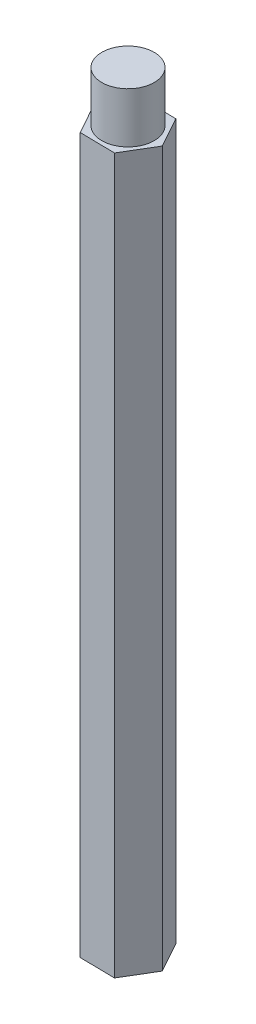
from build123d import *

# Parameters (mm, degrees)
BOSS_EXTRUDE1_DEPTH = 45
SKETCH2_R           = 1.65
BOSS_EXTRUDE2_DEPTH = 3.175


with BuildPart() as part:
    # Sketch1 → Boss-Extrude1 (new body)
    with BuildSketch(Plane(origin=(0, 0, 0), x_dir=(1, 0, 0), z_dir=(0, 1, 0))):
        Polygon((1.066960027, -1.917010598), (2.193659891, -0.034490811), (1.126699864, 1.882519787), (-1.066960027, 1.917010598), (-2.193659891, 0.034490811), (-1.126699864, -1.882519787), align=None)
    extrude(amount=BOSS_EXTRUDE1_DEPTH)

    # Sketch2 → Boss-Extrude2 (add)
    with BuildSketch(Plane(origin=(0, 45, 0), x_dir=(1, 0, 0), z_dir=(0, 1, 0))):
        Circle(SKETCH2_R)
    extrude(amount=BOSS_EXTRUDE2_DEPTH)


solid = part.part
